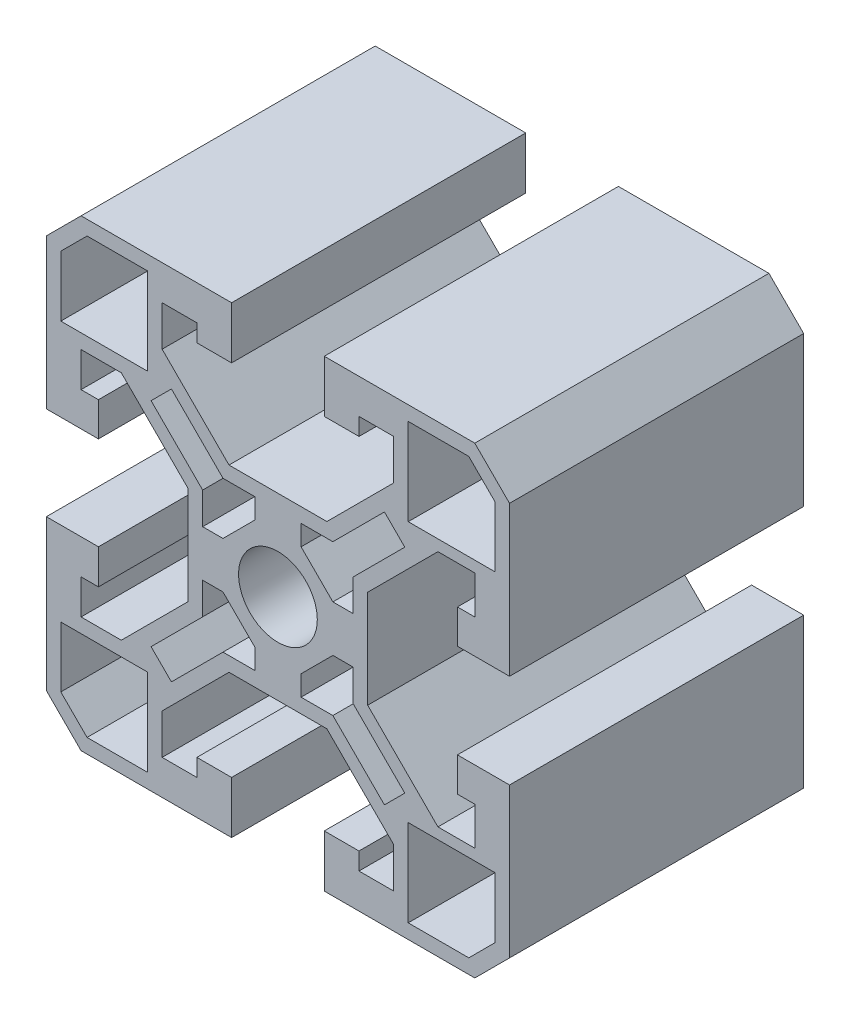
from build123d import *

# Parameters (mm, degrees)
SKETCH1_R      = 3.4
EXTRUDE1_DEPTH = 25.4


with BuildPart() as part:
    # Sketch1 → Extrude1 (new body)
    with BuildSketch(Plane.XY):
        Polygon((4.225, 7.75), (-4.225, 7.75), (-10, 13.525), (-10, 17), (-7, 17), (-7, 15.5), (-4, 15.5), (-4, 20), (-17, 20), (-20, 17), (-20, 4.0635), (-15.5, 4.0635), (-15.5, 7), (-17, 7), (-17, 10), (-13.525, 10), (-7.75, 4.225), (-7.75, -4.225), (-13.525, -10), (-17, -10), (-17, -7), (-15.5, -7), (-15.5, -4), (-20, -4), (-20, -17), (-17, -20), (-4, -20), (-4, -15.5), (-7, -15.5), (-7, -17), (-10, -17), (-10, -13.525), (-4.225, -7.75), (4.225, -7.75), (10, -13.525), (10, -17), (7, -17), (7, -15.5), (4, -15.5), (4, -20), (17, -20), (20, -17), (20, -4.0635), (15.5, -4.0635), (15.5, -7), (17, -7), (17, -10.2921), (13.8171, -10.2921), (7.75, -4.225), (7.75, 4.225), (13.8171, 10.2921), (17, 10.2921), (17, 7), (15.5, 7), (15.5, 4.0635), (20, 4.0635), (20, 17), (17, 20), (4, 20), (4, 15.5), (7, 15.5), (7, 17), (10, 17), (10, 13.525), align=None)
        Circle(SKETCH1_R, mode=Mode.SUBTRACT)
        Polygon((-18.75, -16.482233), (-16.482233, -18.75), (-11.25, -18.75), (-11.25, -11.25), (-18.75, -11.25), align=None, mode=Mode.SUBTRACT)
        Polygon((18.75, 16.482233), (16.482233, 18.75), (11.25, 18.75), (11.25, 11.25), (18.75, 11.25), align=None, mode=Mode.SUBTRACT)
        Polygon((2, -6.5), (4.742767, -6.5), (9.197655, -10.954888), (10.954888, -9.197655), (6.5, -4.742767), (6.5, -2), (4.745788, -2), (2, -4.745788), align=None, mode=Mode.SUBTRACT)
        Polygon((6.5, 2), (6.5, 4.742767), (10.954888, 9.197655), (9.197655, 10.954888), (4.742767, 6.5), (2, 6.5), (2, 4.745788), (4.745788, 2), align=None, mode=Mode.SUBTRACT)
        Polygon((-2, 6.5), (-4.742767, 6.5), (-9.197655, 10.954888), (-10.954888, 9.197655), (-6.5, 4.742767), (-6.5, 2), (-4.745788, 2), (-2, 4.745788), align=None, mode=Mode.SUBTRACT)
        Polygon((-6.5, -2), (-6.5, -4.742767), (-10.954888, -9.197655), (-9.197655, -10.954888), (-4.742767, -6.5), (-2, -6.5), (-2, -4.745788), (-4.745788, -2), align=None, mode=Mode.SUBTRACT)
        Polygon((-16.482233, 18.75), (-18.75, 16.482233), (-18.75, 11.25), (-11.25, 11.25), (-11.25, 18.75), align=None, mode=Mode.SUBTRACT)
        Polygon((16.482233, -18.75), (18.75, -16.482233), (18.75, -11.25), (11.25, -11.25), (11.25, -18.75), align=None, mode=Mode.SUBTRACT)
    extrude(amount=EXTRUDE1_DEPTH)


solid = part.part
